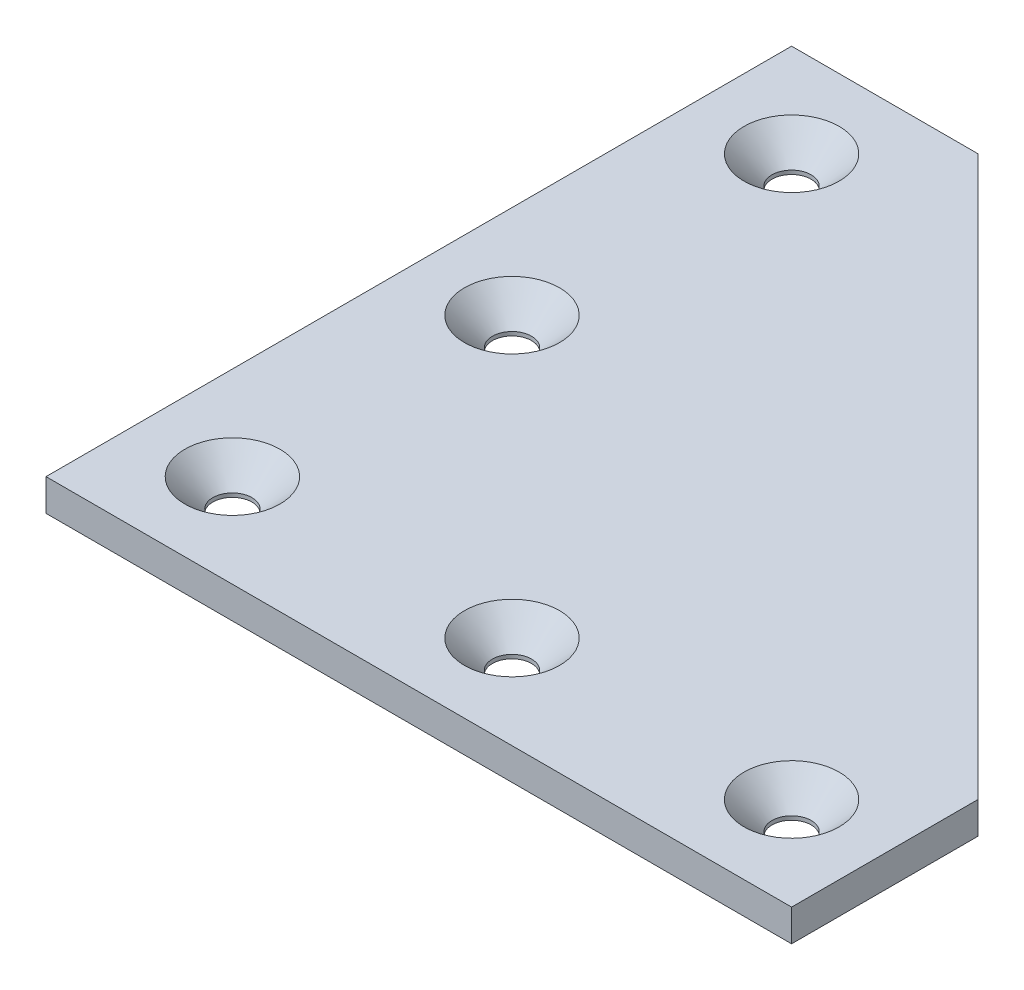
from build123d import *

# Parameters (mm, degrees)
BOSS_EXTRUDE1_DEPTH = 3.416
SKETCH3_R           = 2.1
CUT_EXTRUDE1_DEPTH  = 4
CHAMFER1_SIZE       = 3


with BuildPart() as part:
    # Sketch1 → Boss-Extrude1 (new body)
    with BuildSketch(Plane(origin=(0, 0, 0), x_dir=(1, 0, 0), z_dir=(0, 1, 0))):
        Polygon((0, 0), (0, 80), (20, 80), (80, 20), (80, 0), align=None)
    extrude(amount=BOSS_EXTRUDE1_DEPTH)

    # Sketch3 → Cut-Extrude1 (cut)
    with BuildSketch(Plane(origin=(0, 3.416, 0), x_dir=(1, 0, 0), z_dir=(0, 1, 0))):
        with Locations((10, 10)):
            Circle(SKETCH3_R)
        with Locations((40, 10)):
            Circle(SKETCH3_R)
        with Locations((70, 10)):
            Circle(SKETCH3_R)
        with Locations((10, 40)):
            Circle(SKETCH3_R)
        with Locations((10, 70)):
            Circle(SKETCH3_R)
    extrude(amount=-CUT_EXTRUDE1_DEPTH, mode=Mode.SUBTRACT)

    # Chamfer1
    chamfer1_edges = [part.edges().sort_by_distance(p)[0] for p in [
        (7.9, 3.416, -70),
        (7.9, 3.416, -40),
        (67.9, 3.416, -10),
        (7.9, 3.416, -10),
        (37.9, 3.416, -10),
    ]]
    chamfer(chamfer1_edges, length=CHAMFER1_SIZE)


solid = part.part
